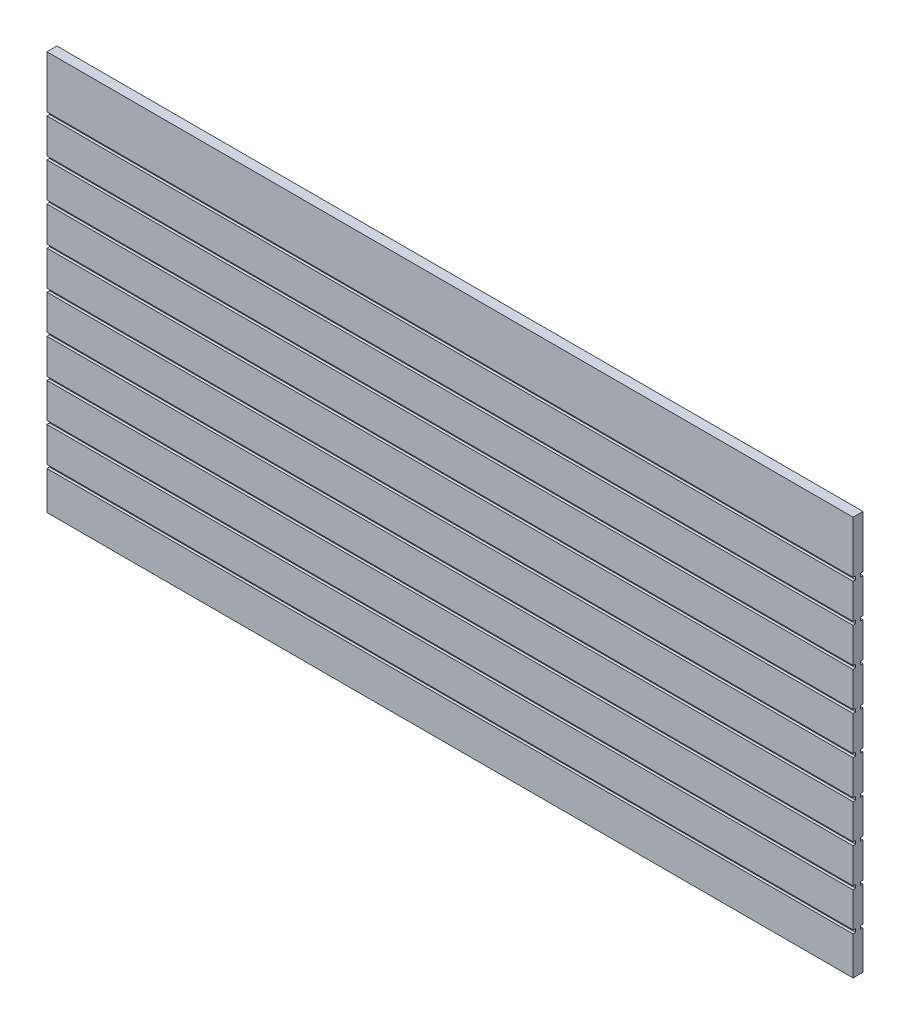
from build123d import *

# Parameters (mm, degrees)
SKETCH1_W                = 1475.316666666
SKETCH1_H                = 730.25
BOSS_EXTRUDE1_DEPTH      = 9.128125
BOSS_EXTRUDE1_DEPTH_BACK = 9.128125
SKETCH2_W                = 1475.316666666
SKETCH2_H                = 6.35
CUT_EXTRUDE1_DEPTH       = 4.7625


with BuildPart() as part:
    # Sketch1 → Boss-Extrude1 (new body, two sides)
    with BuildSketch(Plane.XY) as boss_extrude1_sk:
        Rectangle(SKETCH1_W, SKETCH1_H)
    extrude(amount=BOSS_EXTRUDE1_DEPTH)
    extrude(boss_extrude1_sk.sketch, amount=-BOSS_EXTRUDE1_DEPTH_BACK)

    # Sketch2 → Cut-Extrude1 (cut)
    with BuildSketch(Plane.XY.offset(9.128125)):
        with Locations((0, -292.1)):
            Rectangle(SKETCH2_W, SKETCH2_H)
        with Locations((0, -222.25)):
            Rectangle(SKETCH2_W, SKETCH2_H)
        with Locations((0, -152.4)):
            Rectangle(SKETCH2_W, SKETCH2_H)
        with Locations((0, -82.55)):
            Rectangle(SKETCH2_W, SKETCH2_H)
        with Locations((0, -12.7)):
            Rectangle(SKETCH2_W, SKETCH2_H)
        with Locations((0, 57.15)):
            Rectangle(SKETCH2_W, SKETCH2_H)
        with Locations((0, 127)):
            Rectangle(SKETCH2_W, SKETCH2_H)
        with Locations((0, 196.85)):
            Rectangle(SKETCH2_W, SKETCH2_H)
        with Locations((0, 266.7)):
            Rectangle(SKETCH2_W, SKETCH2_H)
    cut_extrude1 = extrude(amount=-CUT_EXTRUDE1_DEPTH, mode=Mode.SUBTRACT)

    # Mirror1: Cut-Extrude1 across plane
    add(cut_extrude1.mirror(Plane.XY), mode=Mode.SUBTRACT)


solid = part.part
